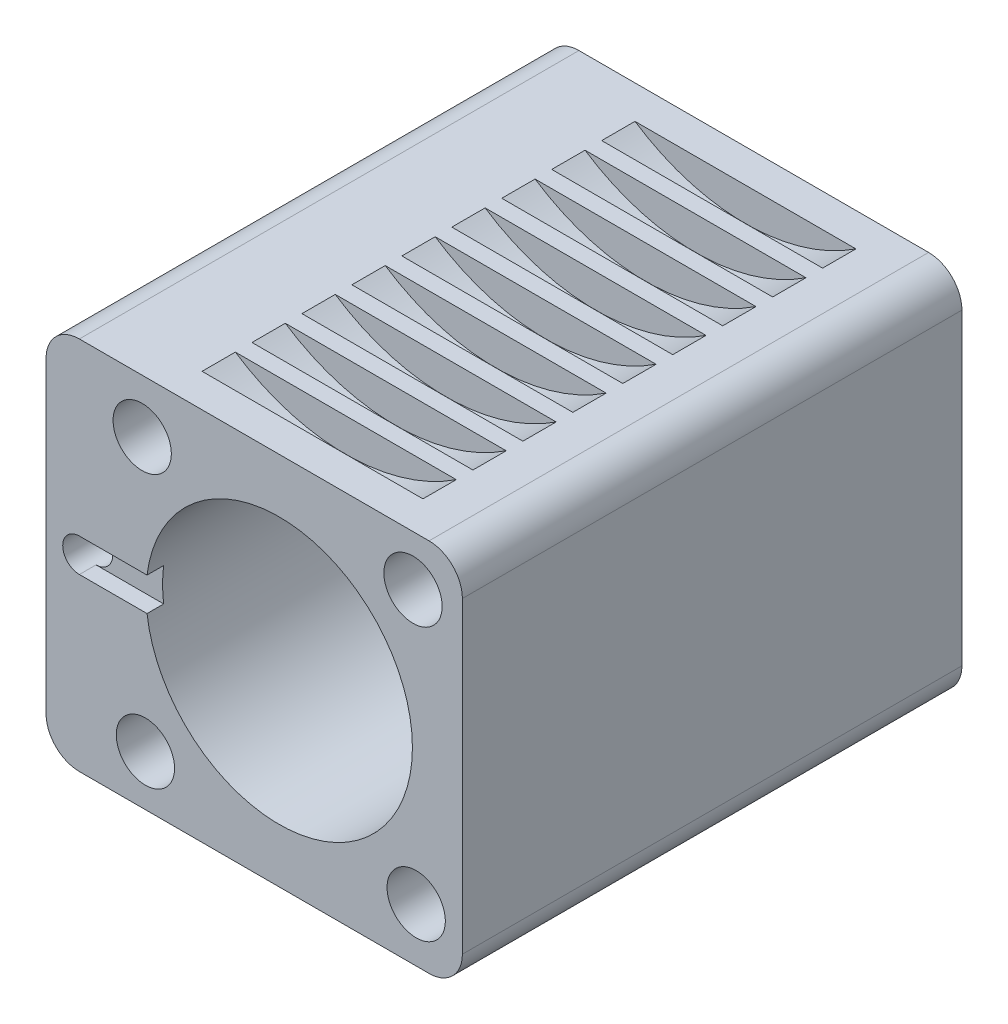
from build123d import *

# Parameters (mm, degrees)
SKETCH1_R               = 16
SKETCH1_R_2             = 3.5
SKETCH1_R_3             = 2
BOSS_EXTRUDE1_DEPTH     = 60
SKETCH2_R               = 18
SKETCH2_R_2             = 16
BOSS_EXTRUDE2_DEPTH     = 2
CUT_EXTRUDE1_DEPTH      = 2
SKETCH6_W               = 4
SKETCH6_H               = 24
LPATTERN1_COUNT         = 9
LPATTERN1_PITCH         = 6
MIRROR1_COPY_1_SKETCH_W = 4
MIRROR1_COPY_1_SKETCH_H = 24
MIRROR1_COPY_2_SKETCH_W = 4
MIRROR1_COPY_2_SKETCH_H = 24
MIRROR1_COPY_3_SKETCH_W = 4
MIRROR1_COPY_3_SKETCH_H = 24
MIRROR1_COPY_4_SKETCH_W = 4
MIRROR1_COPY_4_SKETCH_H = 24
MIRROR1_COPY_5_SKETCH_W = 4
MIRROR1_COPY_5_SKETCH_H = 24
MIRROR1_COPY_6_SKETCH_W = 4
MIRROR1_COPY_6_SKETCH_H = 24
MIRROR1_COPY_7_SKETCH_W = 4
MIRROR1_COPY_7_SKETCH_H = 24
MIRROR1_COPY_8_SKETCH_W = 4
MIRROR1_COPY_8_SKETCH_H = 24


with BuildPart() as part:
    # Sketch1 → Boss-Extrude1 (new body)
    with BuildSketch(Plane.XY):
        with BuildLine():
            Line((-24, 22.5), (18, 22.5))
            ThreePointArc((18, 22.5), (20.828427125, 21.328427125), (22, 18.5))
            Line((22, 18.5), (22, -18.5))
            ThreePointArc((22, -18.5), (20.828427125, -21.328427125), (18, -22.5))
            Line((18, -22.5), (-24, -22.5))
            ThreePointArc((-24, -22.5), (-26.828427125, -21.328427125), (-28, -18.5))
            Line((-28, -18.5), (-28, 18.5))
            ThreePointArc((-28, 18.5), (-26.828427125, 21.328427125), (-24, 22.5))
        make_face()
        Circle(SKETCH1_R, mode=Mode.SUBTRACT)
        with Locations((16.069433567, 16.455190818)):
            Circle(SKETCH1_R_2, mode=Mode.SUBTRACT)
        with Locations((16.455190818, -16.069433567)):
            Circle(SKETCH1_R_2, mode=Mode.SUBTRACT)
        with Locations((-16.069433567, -16.455190818)):
            Circle(SKETCH1_R_2, mode=Mode.SUBTRACT)
        with Locations((-16.455190818, 16.069433567)):
            Circle(SKETCH1_R_2, mode=Mode.SUBTRACT)
        with Locations((-24, 0)):
            Circle(SKETCH1_R_3, mode=Mode.SUBTRACT)
    extrude(amount=BOSS_EXTRUDE1_DEPTH)

    # Sketch2 → Boss-Extrude2 (add)
    with BuildSketch(Plane(origin=(0, 0, 0), x_dir=(-1, 0, 0), z_dir=(0, 0, -1))):
        Circle(SKETCH2_R)
        Circle(SKETCH2_R_2, mode=Mode.SUBTRACT)
    extrude(amount=BOSS_EXTRUDE2_DEPTH)

    # Sketch3 → Cut-Extrude1 (cut)
    with BuildSketch(Plane.XY.offset(60)):
        with BuildLine():
            Line((-24, -2), (-15.874507866, -2))
            ThreePointArc((-15.874507866, -2), (-16, 0), (-15.874507866, 2))
            Line((-15.874507866, 2), (-24, 2))
            ThreePointArc((-24, 2), (-22.585786438, 1.414213562), (-22, 0))
            ThreePointArc((-22, 0), (-22.585786438, -1.414213562), (-24, -2))
        make_face()
    extrude(amount=-CUT_EXTRUDE1_DEPTH, mode=Mode.SUBTRACT)

    # Sketch6 → Cut-Revolve1 (revolve, cut)
    with BuildSketch(Plane(origin=(0, 0, 0), x_dir=(0, 0, -1), z_dir=(1, 0, 0))):
        with Locations((-54, 30.5)):
            Rectangle(SKETCH6_W, SKETCH6_H)
    cut_revolve1 = revolve(axis=Axis((0, 42.5, 56), (0, 0, -1)), mode=Mode.SUBTRACT)

    # LPattern1: Cut-Revolve1 ×9
    with Locations(*[(0, 0, -i * LPATTERN1_PITCH) for i in range(1, LPATTERN1_COUNT)]):
        add(cut_revolve1, mode=Mode.SUBTRACT)

    # Mirror1: Cut-Revolve1 across plane
    add(cut_revolve1.mirror(Plane.ZX), mode=Mode.SUBTRACT)

    # Mirror1 copy 1 sketch → Mirror1 copy 1 (revolve, cut)
    with BuildSketch(Plane(origin=(0, 0, -6), x_dir=(0, 0, -1), z_dir=(1, 0, 0))):
        with Locations((-54, -30.5)):
            Rectangle(MIRROR1_COPY_1_SKETCH_W, MIRROR1_COPY_1_SKETCH_H)
    revolve(axis=Axis((0, -42.5, 50), (0, 0, 1)), mode=Mode.SUBTRACT)

    # Mirror1 copy 2 sketch → Mirror1 copy 2 (revolve, cut)
    with BuildSketch(Plane(origin=(0, 0, -12), x_dir=(0, 0, -1), z_dir=(1, 0, 0))):
        with Locations((-54, -30.5)):
            Rectangle(MIRROR1_COPY_2_SKETCH_W, MIRROR1_COPY_2_SKETCH_H)
    revolve(axis=Axis((0, -42.5, 44), (0, 0, 1)), mode=Mode.SUBTRACT)

    # Mirror1 copy 3 sketch → Mirror1 copy 3 (revolve, cut)
    with BuildSketch(Plane(origin=(0, 0, -18), x_dir=(0, 0, -1), z_dir=(1, 0, 0))):
        with Locations((-54, -30.5)):
            Rectangle(MIRROR1_COPY_3_SKETCH_W, MIRROR1_COPY_3_SKETCH_H)
    revolve(axis=Axis((0, -42.5, 38), (0, 0, 1)), mode=Mode.SUBTRACT)

    # Mirror1 copy 4 sketch → Mirror1 copy 4 (revolve, cut)
    with BuildSketch(Plane(origin=(0, 0, -24), x_dir=(0, 0, -1), z_dir=(1, 0, 0))):
        with Locations((-54, -30.5)):
            Rectangle(MIRROR1_COPY_4_SKETCH_W, MIRROR1_COPY_4_SKETCH_H)
    revolve(axis=Axis((0, -42.5, 32), (0, 0, 1)), mode=Mode.SUBTRACT)

    # Mirror1 copy 5 sketch → Mirror1 copy 5 (revolve, cut)
    with BuildSketch(Plane(origin=(0, 0, -30), x_dir=(0, 0, -1), z_dir=(1, 0, 0))):
        with Locations((-54, -30.5)):
            Rectangle(MIRROR1_COPY_5_SKETCH_W, MIRROR1_COPY_5_SKETCH_H)
    revolve(axis=Axis((0, -42.5, 26), (0, 0, 1)), mode=Mode.SUBTRACT)

    # Mirror1 copy 6 sketch → Mirror1 copy 6 (revolve, cut)
    with BuildSketch(Plane(origin=(0, 0, -36), x_dir=(0, 0, -1), z_dir=(1, 0, 0))):
        with Locations((-54, -30.5)):
            Rectangle(MIRROR1_COPY_6_SKETCH_W, MIRROR1_COPY_6_SKETCH_H)
    revolve(axis=Axis((0, -42.5, 20), (0, 0, 1)), mode=Mode.SUBTRACT)

    # Mirror1 copy 7 sketch → Mirror1 copy 7 (revolve, cut)
    with BuildSketch(Plane(origin=(0, 0, -42), x_dir=(0, 0, -1), z_dir=(1, 0, 0))):
        with Locations((-54, -30.5)):
            Rectangle(MIRROR1_COPY_7_SKETCH_W, MIRROR1_COPY_7_SKETCH_H)
    revolve(axis=Axis((0, -42.5, 14), (0, 0, 1)), mode=Mode.SUBTRACT)

    # Mirror1 copy 8 sketch → Mirror1 copy 8 (revolve, cut)
    with BuildSketch(Plane(origin=(0, 0, -48), x_dir=(0, 0, -1), z_dir=(1, 0, 0))):
        with Locations((-54, -30.5)):
            Rectangle(MIRROR1_COPY_8_SKETCH_W, MIRROR1_COPY_8_SKETCH_H)
    revolve(axis=Axis((0, -42.5, 8), (0, 0, 1)), mode=Mode.SUBTRACT)


solid = part.part
